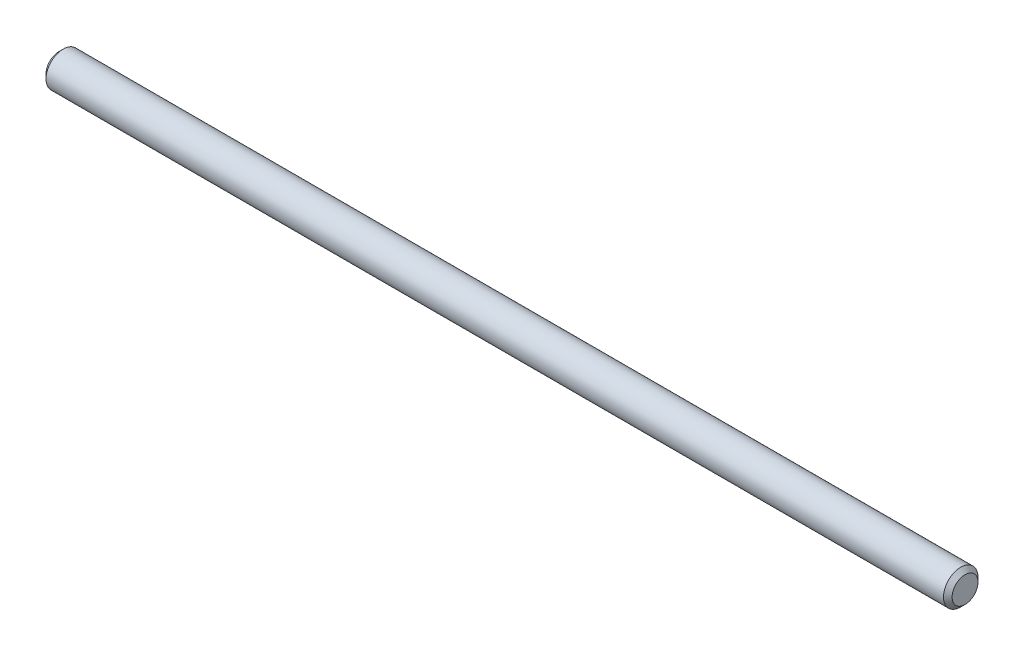
from build123d import *

# Parameters (mm, degrees)
SKETCH1_R           = 2
BOSS_EXTRUDE1_DEPTH = 105
CHAMFER1_SIZE       = 0.5
CHAMFER2_SIZE       = 0.5


with BuildPart() as part:
    # Sketch1 → Boss-Extrude1 (new body)
    with BuildSketch(Plane(origin=(0, 0, 0), x_dir=(0, 0, -1), z_dir=(1, 0, 0))):
        Circle(SKETCH1_R)
    extrude(amount=BOSS_EXTRUDE1_DEPTH)

    # Chamfer1
    chamfer1_edges = [part.edges().sort_by_distance(p)[0] for p in [
        (0, 0, 2),
    ]]
    chamfer(chamfer1_edges, length=CHAMFER1_SIZE)

    # Chamfer2
    chamfer2_edges = [part.edges().sort_by_distance(p)[0] for p in [
        (105, 0, 2),
    ]]
    chamfer(chamfer2_edges, length=CHAMFER2_SIZE)


solid = part.part
